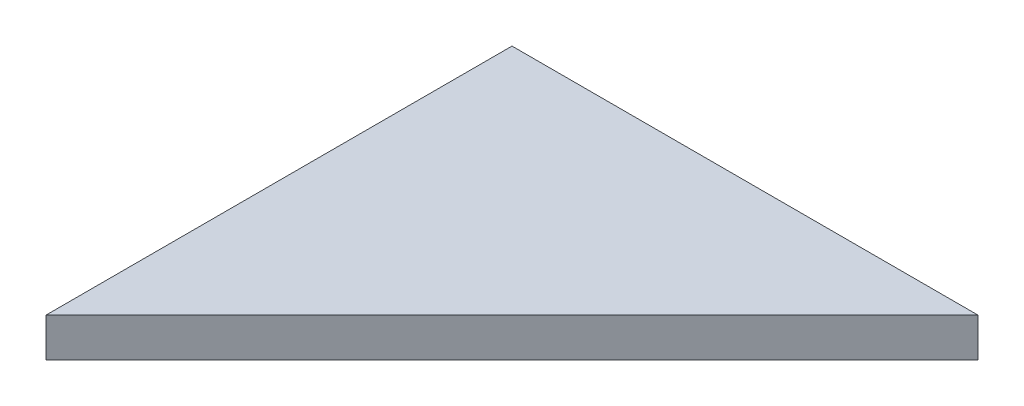
from build123d import *

# Parameters (mm, degrees)
BOSS_EXTRUDE1_DEPTH = 1.5875


with BuildPart() as part:
    # Sketch1 → Boss-Extrude1 (new body, symmetric)
    with BuildSketch(Plane(origin=(0, 0, 0), x_dir=(1, 0, 0), z_dir=(0, 1, 0))):
        Polygon((38.1, 0), (0, 0), (0, -38.1), align=None)
    extrude(amount=BOSS_EXTRUDE1_DEPTH, both=True)


solid = part.part
